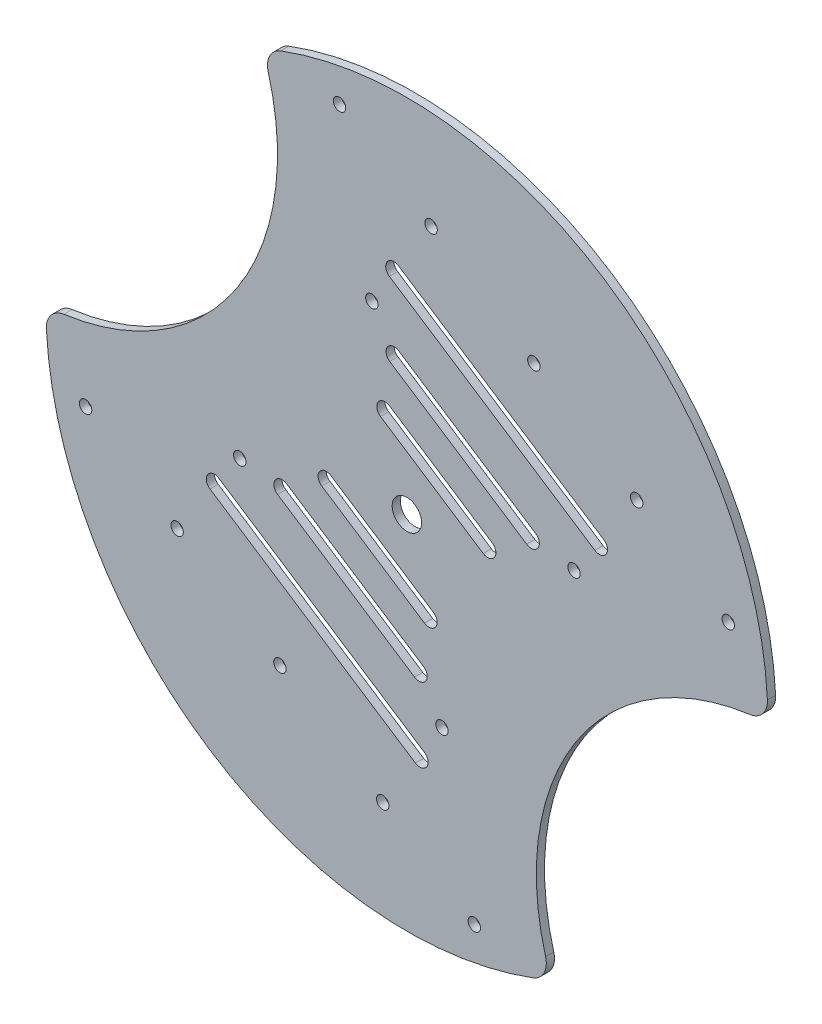
from build123d import *

# Parameters (mm, degrees)
SKETCH_1_R      = 1.52
SKETCH_1_R_2    = 1.519999991
SKETCH_1_R_3    = 1.520000009
SKETCH_1_R_4    = 1.520000002
SKETCH_1_R_5    = 3.6
SKETCH_1_R_6    = 1.517381685
SKETCH_1_R_7    = 1.519999997
EXTRUDE_1_DEPTH = 2
FILLET_1_R      = 5


with BuildPart() as part:
    # 草图1 → 凸台-拉伸1 (new body)
    with BuildSketch(Plane.XY):
        with BuildLine():
            ThreePointArc((71.75669201, 78.511901277), (31.878575622, 152.307394815), (-51.703250679, 159.386755327))
            ThreePointArc((-51.703250679, 159.386755327), (-57.956662012, 105.693394177), (-104.68190817, 78.511901277))
            ThreePointArc((-104.68190817, 78.511901277), (-64.803791783, 4.716407738), (18.778034519, -2.362952773))
            ThreePointArc((18.778034519, -2.362952773), (25.031445851, 51.330408377), (71.75669201, 78.511901277))
        make_face()
        with Locations((-94.974509357, 62.049293197)):
            Circle(SKETCH_1_R, mode=Mode.SUBTRACT)
        Circle(SKETCH_1_R, mode=Mode.SUBTRACT)
        with Locations((-32.925216161, 157.023802554)):
            Circle(SKETCH_1_R, mode=Mode.SUBTRACT)
        with Locations((62.049293197, 94.974509357)):
            Circle(SKETCH_1_R, mode=Mode.SUBTRACT)
        with Locations((-47.487254679, 31.024646598)):
            Circle(SKETCH_1_R_2, mode=Mode.SUBTRACT)
        with Locations((-22.372181549, 14.61632244)):
            Circle(SKETCH_1_R_3, mode=Mode.SUBTRACT)
        with Locations((-72.602327809, 47.432970756)):
            Circle(SKETCH_1_R_3, mode=Mode.SUBTRACT)
        with BuildLine():
            ThreePointArc((-12.190085291, 30.286229165), (-11.613016331, 27.517295901), (-14.381949595, 26.940226942))
            Line((-14.381949595, 26.940226942), (-64.57198293, 59.818191506))
            ThreePointArc((-64.57198293, 59.818191506), (-65.149051889, 62.587124769), (-62.380118626, 63.164193728))
            Line((-62.380118626, 63.164193728), (-12.190085291, 30.286229165))
        make_face(mode=Mode.SUBTRACT)
        with Locations((-57.293948747, 69.950264788)):
            Circle(SKETCH_1_R_4, mode=Mode.SUBTRACT)
        with BuildLine():
            ThreePointArc((-12.40781803, 48.360410386), (-11.830749071, 45.591477123), (-14.599682334, 45.014408164))
            Line((-14.599682334, 45.014408164), (-48.059704557, 66.933051206))
            ThreePointArc((-48.059704557, 66.933051206), (-48.636773516, 69.70198447), (-45.867840253, 70.279053429))
            Line((-45.867840253, 70.279053429), (-12.40781803, 48.360410386))
        make_face(mode=Mode.SUBTRACT)
        with BuildLine():
            ThreePointArc((-9.979365756, 61.005797168), (-9.402296797, 58.236863905), (-12.17123006, 57.659794946))
            Line((-12.17123006, 57.659794946), (-37.266246728, 74.098777228))
            ThreePointArc((-37.266246728, 74.098777228), (-37.843315687, 76.867710491), (-35.074382424, 77.44477945))
            Line((-35.074382424, 77.44477945), (-9.979365756, 61.005797168))
        make_face(mode=Mode.SUBTRACT)
        with Locations((-7.900971591, 37.68056061)):
            Circle(SKETCH_1_R, mode=Mode.SUBTRACT)
        with Locations((-25.024244569, 119.343241944)):
            Circle(SKETCH_1_R, mode=Mode.SUBTRACT)
        with Locations((-16.46260808, 78.511901277)):
            Circle(SKETCH_1_R_5, mode=Mode.SUBTRACT)
        with BuildLine():
            Line((-20.727239862, 99.346486961), (4.367776805, 82.907504679))
            ThreePointArc((4.367776805, 82.907504679), (4.944845764, 80.138571416), (2.175912501, 79.561502457))
            Line((2.175912501, 79.561502457), (-22.919104167, 96.000484738))
            ThreePointArc((-22.919104167, 96.000484738), (-23.496173126, 98.769418002), (-20.727239862, 99.346486961))
        make_face(mode=Mode.SUBTRACT)
        with BuildLine():
            Line((-18.469699209, 112.103832748), (14.990323014, 90.185189705))
            ThreePointArc((14.990323014, 90.185189705), (15.567391973, 87.416256442), (12.79845871, 86.839187483))
            Line((12.79845871, 86.839187483), (-20.661563513, 108.757830525))
            ThreePointArc((-20.661563513, 108.757830525), (-21.238632472, 111.526763789), (-18.469699209, 112.103832748))
        make_face(mode=Mode.SUBTRACT)
        with Locations((24.368732586, 87.073537766)):
            Circle(SKETCH_1_R_6, mode=Mode.SUBTRACT)
        with BuildLine():
            Line((-18.543266566, 130.083575612), (31.646766769, 97.205611048))
            ThreePointArc((31.646766769, 97.205611048), (32.223835728, 94.436677785), (29.454902465, 93.859608826))
            Line((29.454902465, 93.859608826), (-20.73513087, 126.737573389))
            ThreePointArc((-20.73513087, 126.737573389), (-21.312199829, 129.506506653), (-18.543266566, 130.083575612))
        make_face(mode=Mode.SUBTRACT)
        with Locations((39.677111648, 109.590831797)):
            Circle(SKETCH_1_R_3, mode=Mode.SUBTRACT)
        with Locations((-10.553034612, 142.407480114)):
            Circle(SKETCH_1_R_3, mode=Mode.SUBTRACT)
        with Locations((14.562038518, 125.999155956)):
            Circle(SKETCH_1_R_7, mode=Mode.SUBTRACT)
    extrude(amount=EXTRUDE_1_DEPTH)

    # 圆角1
    fillet_1_edges = [part.edges().sort_by_distance(p)[0] for p in [
        (71.75669201, 78.511901277, 1),
        (18.778034519, -2.362952773, 1),
        (-104.68190817, 78.511901277, 1),
        (-51.703250679, 159.386755327, 1),
    ]]
    fillet(fillet_1_edges, radius=FILLET_1_R)


solid = part.part
